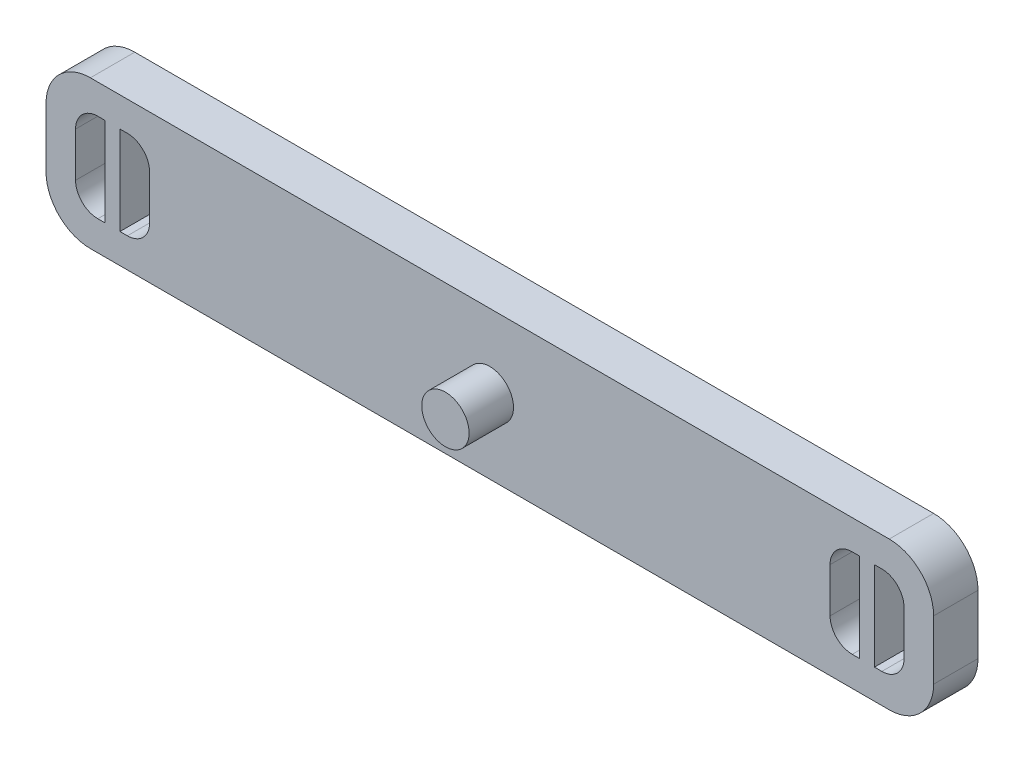
from build123d import *

# Parameters (mm, degrees)
SKETCH1_W           = 60
SKETCH1_H           = 10
BOSS_EXTRUDE1_DEPTH = 3
CUT_EXTRUDE2_DEPTH  = 3
FILLET1_R           = 3
SKETCH2_R           = 1.6
BOSS_EXTRUDE2_DEPTH = 3


with BuildPart() as part:
    # Sketch1 → Boss-Extrude1 (new body)
    with BuildSketch(Plane.XY):
        Rectangle(SKETCH1_W, SKETCH1_H)
    extrude(amount=BOSS_EXTRUDE1_DEPTH)

    # Sketch3 → Cut-Extrude2 (cut)
    with BuildSketch(Plane.XY.offset(3)):
        with BuildLine():
            Line((-26.5, 3), (-26, 3))
            Line((-26, 3), (-26, -3))
            Line((-26, -3), (-26.5, -3))
            ThreePointArc((-26.5, -3), (-27.560660172, -2.560660172), (-28, -1.5))
            Line((-28, -1.5), (-28, 1.5))
            ThreePointArc((-28, 1.5), (-27.560660172, 2.560660172), (-26.5, 3))
        make_face()
        with BuildLine():
            Line((-25, 3), (-24.5, 3))
            ThreePointArc((-24.5, 3), (-23.439339828, 2.560660172), (-23, 1.5))
            Line((-23, 1.5), (-23, -1.5))
            ThreePointArc((-23, -1.5), (-23.439339828, -2.560660172), (-24.5, -3))
            Line((-24.5, -3), (-25, -3))
            Line((-25, -3), (-25, 3))
        make_face()
    cut_extrude2 = extrude(amount=-CUT_EXTRUDE2_DEPTH, mode=Mode.SUBTRACT)

    # Mirror1: Cut-Extrude2 across plane
    add(cut_extrude2.mirror(Plane(origin=(0, 0, 0), x_dir=(0, 0, 1), z_dir=(1, 0, 0))), mode=Mode.SUBTRACT)

    # Fillet1
    fillet1_edges = [part.edges().sort_by_distance(p)[0] for p in [
        (30, -5, 1.5),
        (-30, -5, 1.5),
        (-30, 5, 1.5),
        (30, 5, 1.5),
    ]]
    fillet(fillet1_edges, radius=FILLET1_R)

    # Sketch2 → Boss-Extrude2 (add)
    with BuildSketch(Plane.XY.offset(3)):
        Circle(SKETCH2_R)
    extrude(amount=BOSS_EXTRUDE2_DEPTH)


solid = part.part
